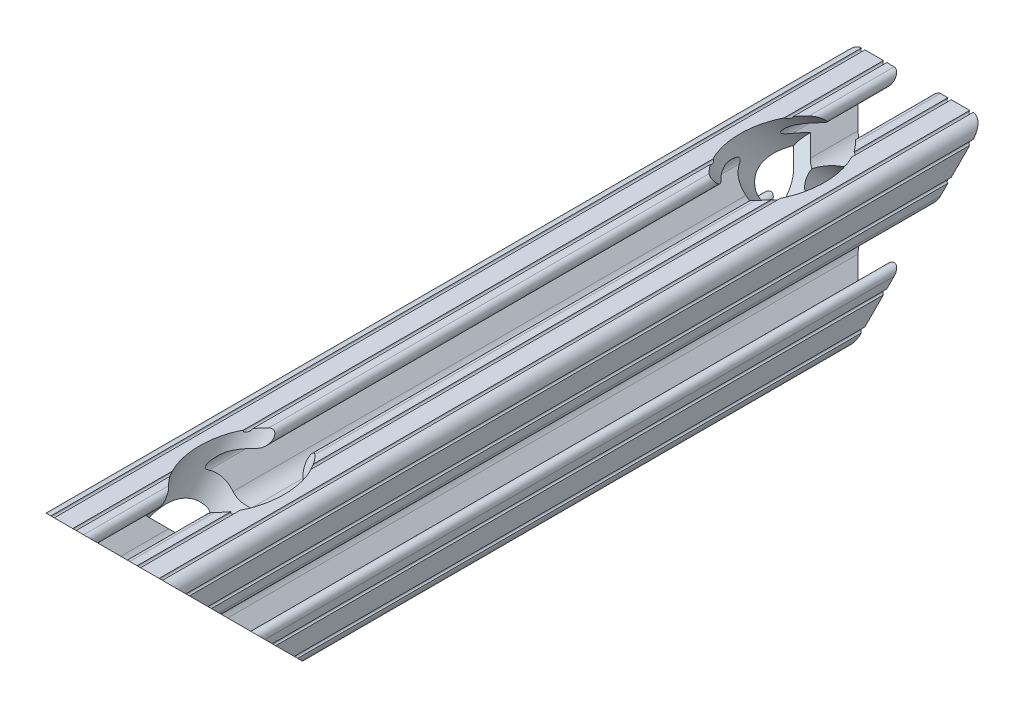
from build123d import *

# Parameters (mm, degrees)
SKETCH3_R          = 2.5781
EXTRUDE1_DEPTH     = 165.1
CUT_EXTRUDE1_DEPTH = 38.1
SKETCH5_R          = 3.2639
CUT_EXTRUDE2_DEPTH = 6.35
SKETCH6_R          = 7.9375
CUT_EXTRUDE3_DEPTH = 102.413073453
SKETCH7_R          = 3.2639
CUT_EXTRUDE4_DEPTH = 6.35
SKETCH8_R          = 7.9375
CUT_EXTRUDE5_DEPTH = 102.413073594


with BuildPart() as part:
    # Sketch3 → Extrude1 (new body, symmetric)
    with BuildSketch(Plane.XY):
        with BuildLine():
            Line((-1.115277175, 4.5085), (1.115277175, 4.5085))
            ThreePointArc((1.115277175, 4.5085), (2.806584872, 4.844922018), (4.240406305, 5.80297087))
            Line((4.240406305, 5.80297087), (7.119225992, 8.681790557))
            ThreePointArc((7.119225992, 8.681790557), (7.348862413, 9.836250802), (6.370158275, 10.4902))
            Line((6.370158275, 10.4902), (4.3434, 10.4902))
            ThreePointArc((4.3434, 10.4902), (3.2385, 11.5951), (4.3434, 12.7))
            Line((4.3434, 12.7), (5.738786846, 12.7))
            ThreePointArc((5.738786846, 12.7), (6.054472561, 12.384314286), (6.370158275, 12.7))
            Line((6.370158275, 12.7), (9.858828571, 12.7))
            ThreePointArc((9.858828571, 12.7), (10.174514286, 12.384314286), (10.4902, 12.7))
            ThreePointArc((10.4902, 12.7), (12.052764565, 12.052764565), (12.7, 10.4902))
            ThreePointArc((12.7, 10.4902), (12.384314286, 10.174514286), (12.7, 9.858828571))
            Line((12.7, 9.858828571), (12.7, 6.370158275))
            ThreePointArc((12.7, 6.370158275), (12.384314286, 6.054472561), (12.7, 5.738786846))
            Line((12.7, 5.738786846), (12.7, 4.3434))
            ThreePointArc((12.7, 4.3434), (11.5951, 3.2385), (10.4902, 4.3434))
            Line((10.4902, 4.3434), (10.4902, 6.370158275))
            ThreePointArc((10.4902, 6.370158275), (9.836250802, 7.348862413), (8.681790557, 7.119225992))
            Line((8.681790557, 7.119225992), (5.80297087, 4.240406305))
            ThreePointArc((5.80297087, 4.240406305), (4.844922018, 2.806584872), (4.5085, 1.115277175))
            Line((4.5085, 1.115277175), (4.5085, -1.115277175))
            ThreePointArc((4.5085, -1.115277175), (4.844922018, -2.806584872), (5.80297087, -4.240406305))
            Line((5.80297087, -4.240406305), (8.681790557, -7.119225992))
            ThreePointArc((8.681790557, -7.119225992), (9.836250802, -7.348862413), (10.4902, -6.370158275))
            Line((10.4902, -6.370158275), (10.4902, -4.3434))
            ThreePointArc((10.4902, -4.3434), (11.5951, -3.2385), (12.7, -4.3434))
            Line((12.7, -4.3434), (12.7, -5.738786846))
            ThreePointArc((12.7, -5.738786846), (12.384314286, -6.054472561), (12.7, -6.370158275))
            Line((12.7, -6.370158275), (12.7, -9.858828571))
            ThreePointArc((12.7, -9.858828571), (12.384314286, -10.174514286), (12.7, -10.4902))
            ThreePointArc((12.7, -10.4902), (12.052764565, -12.052764565), (10.4902, -12.7))
            ThreePointArc((10.4902, -12.7), (10.174514286, -12.384314286), (9.858828571, -12.7))
            Line((9.858828571, -12.7), (6.370158275, -12.7))
            ThreePointArc((6.370158275, -12.7), (6.054472561, -12.384314286), (5.738786846, -12.7))
            Line((5.738786846, -12.7), (4.3434, -12.7))
            ThreePointArc((4.3434, -12.7), (3.2385, -11.5951), (4.3434, -10.4902))
            Line((4.3434, -10.4902), (6.370158275, -10.4902))
            ThreePointArc((6.370158275, -10.4902), (7.348862413, -9.836250802), (7.119225992, -8.681790557))
            Line((7.119225992, -8.681790557), (4.240406305, -5.80297087))
            ThreePointArc((4.240406305, -5.80297087), (2.806584872, -4.844922018), (1.115277175, -4.5085))
            Line((1.115277175, -4.5085), (-1.115277175, -4.5085))
            ThreePointArc((-1.115277175, -4.5085), (-2.806584872, -4.844922018), (-4.240406305, -5.80297087))
            Line((-4.240406305, -5.80297087), (-7.119225992, -8.681790557))
            ThreePointArc((-7.119225992, -8.681790557), (-7.348862413, -9.836250802), (-6.370158275, -10.4902))
            Line((-6.370158275, -10.4902), (-4.3434, -10.4902))
            ThreePointArc((-4.3434, -10.4902), (-3.2385, -11.5951), (-4.3434, -12.7))
            Line((-4.3434, -12.7), (-5.738786846, -12.7))
            ThreePointArc((-5.738786846, -12.7), (-6.054472561, -12.384314286), (-6.370158275, -12.7))
            Line((-6.370158275, -12.7), (-9.858828571, -12.7))
            ThreePointArc((-9.858828571, -12.7), (-10.174514286, -12.384314286), (-10.4902, -12.7))
            ThreePointArc((-10.4902, -12.7), (-12.052764565, -12.052764565), (-12.7, -10.4902))
            ThreePointArc((-12.7, -10.4902), (-12.384314286, -10.174514286), (-12.7, -9.858828571))
            Line((-12.7, -9.858828571), (-12.7, -6.370158275))
            ThreePointArc((-12.7, -6.370158275), (-12.384314286, -6.054472561), (-12.7, -5.738786846))
            Line((-12.7, -5.738786846), (-12.7, -4.3434))
            ThreePointArc((-12.7, -4.3434), (-11.5951, -3.2385), (-10.4902, -4.3434))
            Line((-10.4902, -4.3434), (-10.4902, -6.370158275))
            ThreePointArc((-10.4902, -6.370158275), (-9.836250802, -7.348862413), (-8.681790557, -7.119225992))
            Line((-8.681790557, -7.119225992), (-5.80297087, -4.240406305))
            ThreePointArc((-5.80297087, -4.240406305), (-4.844922018, -2.806584872), (-4.5085, -1.115277175))
            Line((-4.5085, -1.115277175), (-4.5085, 1.115277175))
            ThreePointArc((-4.5085, 1.115277175), (-4.844922018, 2.806584872), (-5.80297087, 4.240406305))
            Line((-5.80297087, 4.240406305), (-8.681790557, 7.119225992))
            ThreePointArc((-8.681790557, 7.119225992), (-9.836250802, 7.348862413), (-10.4902, 6.370158275))
            Line((-10.4902, 6.370158275), (-10.4902, 4.3434))
            ThreePointArc((-10.4902, 4.3434), (-11.5951, 3.2385), (-12.7, 4.3434))
            Line((-12.7, 4.3434), (-12.7, 5.738786846))
            ThreePointArc((-12.7, 5.738786846), (-12.384314286, 6.054472561), (-12.7, 6.370158275))
            Line((-12.7, 6.370158275), (-12.7, 9.858828571))
            ThreePointArc((-12.7, 9.858828571), (-12.384314286, 10.174514286), (-12.7, 10.4902))
            ThreePointArc((-12.7, 10.4902), (-12.052764565, 12.052764565), (-10.4902, 12.7))
            ThreePointArc((-10.4902, 12.7), (-10.174514286, 12.384314286), (-9.858828571, 12.7))
            Line((-9.858828571, 12.7), (-6.370158275, 12.7))
            ThreePointArc((-6.370158275, 12.7), (-6.054472561, 12.384314286), (-5.738786846, 12.7))
            Line((-5.738786846, 12.7), (-4.3434, 12.7))
            ThreePointArc((-4.3434, 12.7), (-3.2385, 11.5951), (-4.3434, 10.4902))
            Line((-4.3434, 10.4902), (-6.370158275, 10.4902))
            ThreePointArc((-6.370158275, 10.4902), (-7.348862413, 9.836250802), (-7.119225992, 8.681790557))
            Line((-7.119225992, 8.681790557), (-4.240406305, 5.80297087))
            ThreePointArc((-4.240406305, 5.80297087), (-2.806584872, 4.844922018), (-1.115277175, 4.5085))
        make_face()
        Circle(SKETCH3_R, mode=Mode.SUBTRACT)
    extrude(amount=EXTRUDE1_DEPTH, both=True)

    # Sketch4 → Cut-Extrude1 (cut, symmetric)
    with BuildSketch(Plane(origin=(0, 0, 0), x_dir=(0, 0, -1), z_dir=(1, 0, 0))):
        Polygon((-165.1, 12.7), (-165.1, -12.7), (-50.8, -12.7), (-76.2, 12.7), align=None)
        Polygon((76.2, 12.7), (50.8, -12.7), (165.1, -12.7), (165.1, 12.7), align=None)
    extrude(amount=CUT_EXTRUDE1_DEPTH, both=True, mode=Mode.SUBTRACT)

    # Sketch5 → Cut-Extrude2 (cut)
    with BuildSketch(Plane(origin=(0, -31.75, 31.75), x_dir=(1, 0, 0), z_dir=(0, -0.707106781, 0.707106781))):
        with Locations((0, 44.901280605)):
            Circle(SKETCH5_R)
    extrude(amount=-CUT_EXTRUDE2_DEPTH, mode=Mode.SUBTRACT)

    # Sketch6 → Cut-Extrude3 (cut, through all)
    with BuildSketch(Plane(origin=(0, -27.259871939, 27.259871939), x_dir=(1, 0, 0), z_dir=(0, -0.707106781, 0.707106781))):
        with Locations((0, 44.901280605)):
            Circle(SKETCH6_R)
    extrude(amount=-CUT_EXTRUDE3_DEPTH, mode=Mode.SUBTRACT)

    # Sketch7 → Cut-Extrude4 (cut)
    with BuildSketch(Plane(origin=(0, -31.75, -31.75), x_dir=(1, 0, 0), z_dir=(0, -0.707106781, -0.707106781))):
        with Locations((0, -44.901280605)):
            Circle(SKETCH7_R)
    extrude(amount=-CUT_EXTRUDE4_DEPTH, mode=Mode.SUBTRACT)

    # Sketch8 → Cut-Extrude5 (cut, through all)
    with BuildSketch(Plane(origin=(0, -27.259871939, -27.259871939), x_dir=(1, 0, 0), z_dir=(0, -0.707106781, -0.707106781))):
        with Locations((0, -44.901280605)):
            Circle(SKETCH8_R)
    extrude(amount=-CUT_EXTRUDE5_DEPTH, mode=Mode.SUBTRACT)


solid = part.part
